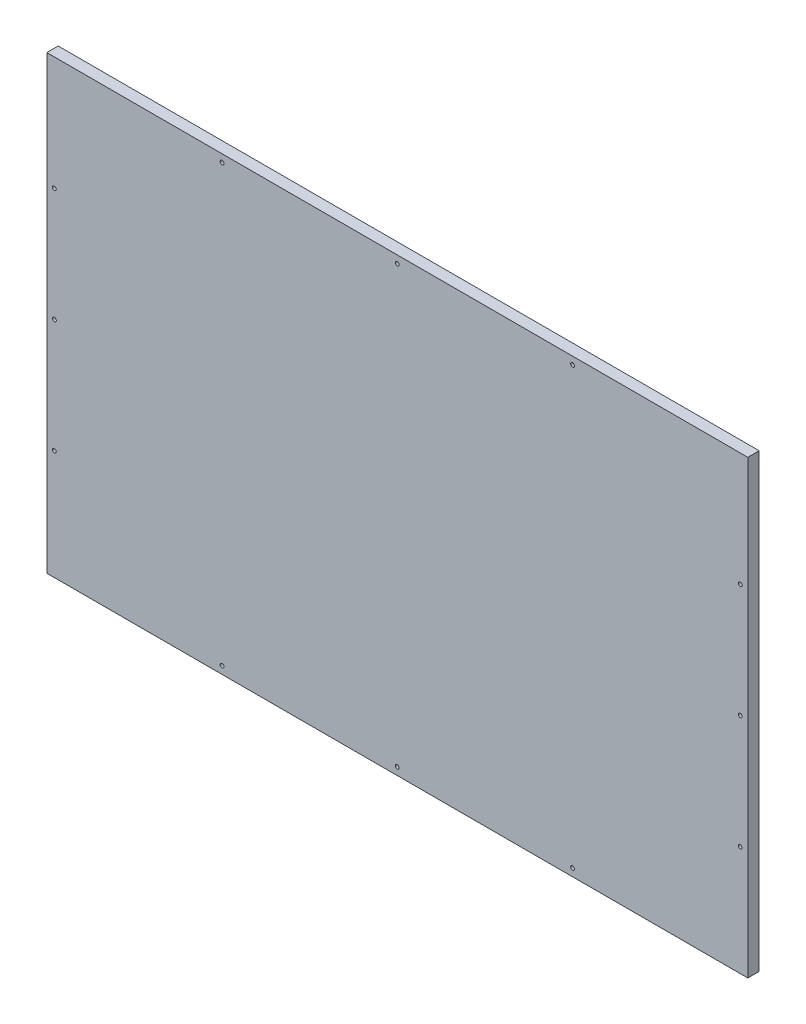
from build123d import *

# Parameters (mm, degrees)
SKETCH_1_W          = 925
SKETCH_1_H          = 595
EXTRUDE_1_DEPTH     = 15
SKETCH_2_R          = 2.5
CUT_EXTRUDE_1_DEPTH = 551.124985799
SKETCH_2_3_R        = 2.5
CUT_EXTRUDE_2_DEPTH = 551.124985799


with BuildPart() as part:
    # ｽｹｯﾁ1 → ﾎﾞｽ - 押し出し1 (new body)
    with BuildSketch(Plane.XY):
        Rectangle(SKETCH_1_W, SKETCH_1_H)
    extrude(amount=EXTRUDE_1_DEPTH)

    # ｽｹｯﾁ2 → ｶｯﾄ - 押し出し1 (cut, through all)
    with BuildSketch(Plane.XY.offset(15)):
        with Locations((-231.25, 287.5)):
            Circle(SKETCH_2_R)
        with Locations((0, 287.5)):
            Circle(SKETCH_2_R)
        with Locations((231.25, 287.5)):
            Circle(SKETCH_2_R)
    cut_extrude_1 = extrude(amount=-CUT_EXTRUDE_1_DEPTH, mode=Mode.SUBTRACT)

    # ｽｹｯﾁ2<3> → ｶｯﾄ - 押し出し2 (cut, through all)
    with BuildSketch(Plane.XY.offset(15)):
        with Locations((-452.5, 147.5)):
            Circle(SKETCH_2_3_R)
        with Locations((-452.5, -2.5)):
            Circle(SKETCH_2_3_R)
        with Locations((-452.5, -152.5)):
            Circle(SKETCH_2_3_R)
    cut_extrude_2 = extrude(amount=-CUT_EXTRUDE_2_DEPTH, mode=Mode.SUBTRACT)

    # ﾐﾗｰ1: ｶｯﾄ - 押し出し1 across plane
    add(cut_extrude_1.mirror(Plane.ZX), mode=Mode.SUBTRACT)

    # ﾐﾗｰ2: ｶｯﾄ - 押し出し2 across plane
    add(cut_extrude_2.mirror(Plane(origin=(0, 0, 0), x_dir=(0, 0, 1), z_dir=(1, 0, 0))), mode=Mode.SUBTRACT)


solid = part.part
